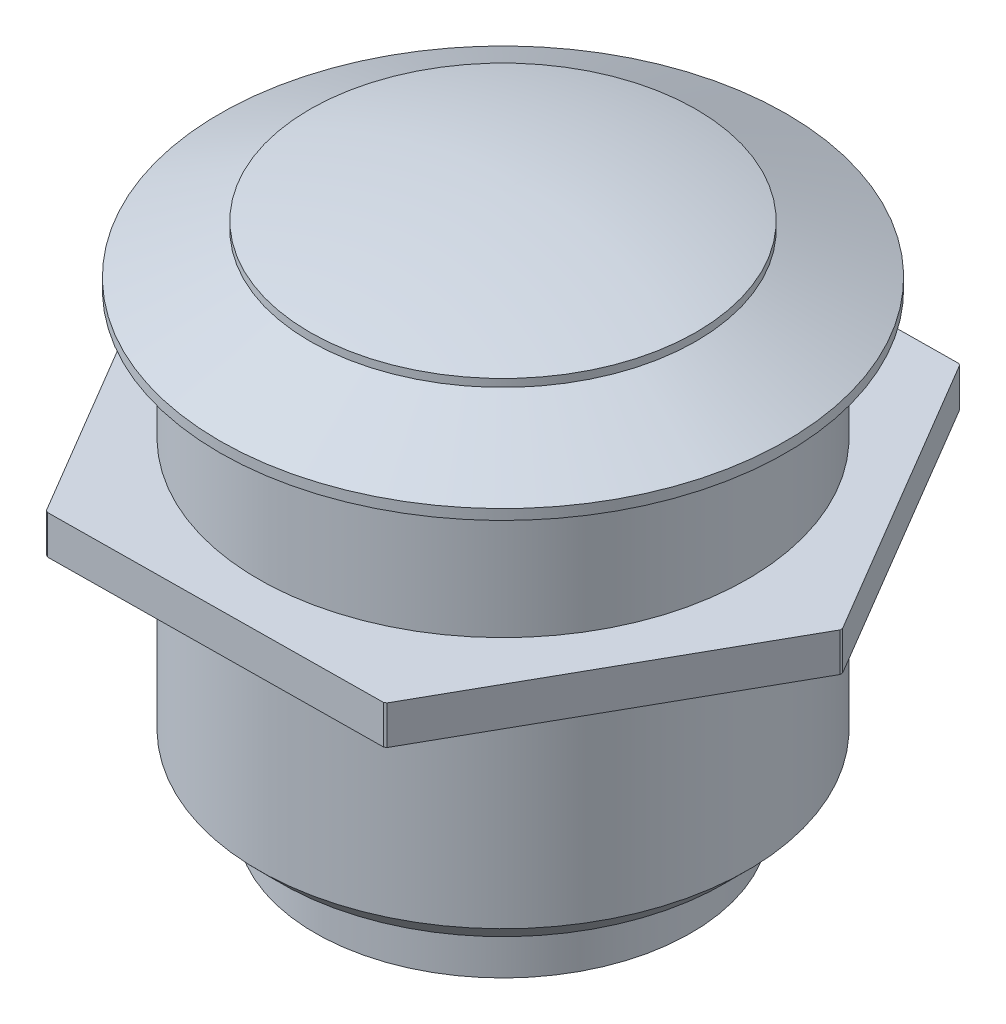
from build123d import *

# Parameters (mm, degrees)
CUT_EXTRUDE1_DEPTH = 14


with BuildPart() as part:
    # Sketch1 → Revolve1 (revolve)
    with BuildSketch(Plane.XY):
        with BuildLine():
            Line((7.5, -1), (7.5, -1.3))
            Line((7.5, -1.3), (11, -2.9))
            Line((11, -2.9), (11, -3.3))
            Line((11, -3.3), (9.5, -3.3))
            Line((9.5, -3.3), (9.5, -8.3))
            Line((9.5, -8.3), (13, -8.3))
            Line((13, -8.3), (13, -9.8))
            Line((13, -9.8), (9.5, -9.8))
            Line((9.5, -9.8), (9.5, -18.088730163))
            Line((9.5, -18.088730163), (8.588730163, -19))
            Line((8.588730163, -19), (7.3, -19))
            Line((7.3, -19), (7.3, -21.3))
            Line((7.3, -21.3), (0, -21.3))
            Line((0, -21.3), (0, 0))
            ThreePointArc((0, 0), (3.781652901, -0.262603245), (7.5, -1))
        make_face()
    revolve(axis=Axis((0, 0, 0), (0, 1, 0)))

    # Sketch2 → Cut-Extrude1 (cut, through all)
    with BuildSketch(Plane(origin=(0, -8.3, 0), x_dir=(1, 0, 0), z_dir=(0, 1, 0))):
        with BuildLine():
            Line((-6.619007915, 11.214265949), (6.380992085, 11.351386108))
            ThreePointArc((6.380992085, 11.351386108), (-0.137343979, 13.021219728), (-6.619007915, 11.214265949))
        make_face()
        with BuildLine():
            Line((6.402335239, 11.339361977), (13.02108478, 0.149591808))
            ThreePointArc((13.02108478, 0.149591808), (11.208035083, 6.629553238), (6.402335239, 11.339361977))
        make_face()
        with BuildLine():
            Line((13.021343155, 0.125096028), (6.640092696, -11.201794301))
            ThreePointArc((6.640092696, -11.201794301), (11.345379062, -6.391666489), (13.021343155, 0.125096028))
        make_face()
        with BuildLine():
            Line((6.619007915, -11.214265949), (-6.380992085, -11.351386108))
            ThreePointArc((-6.380992085, -11.351386108), (0.137343979, -13.021219728), (6.619007915, -11.214265949))
        make_face()
        with BuildLine():
            Line((-6.402335239, -11.339361977), (-13.02108478, -0.149591808))
            ThreePointArc((-13.02108478, -0.149591808), (-11.208035083, -6.629553238), (-6.402335239, -11.339361977))
        make_face()
        with BuildLine():
            Line((-13.021343155, -0.125096028), (-6.640092696, 11.201794301))
            ThreePointArc((-6.640092696, 11.201794301), (-11.345379062, 6.391666489), (-13.021343155, -0.125096028))
        make_face()
    extrude(amount=-CUT_EXTRUDE1_DEPTH, mode=Mode.SUBTRACT)


solid = part.part
